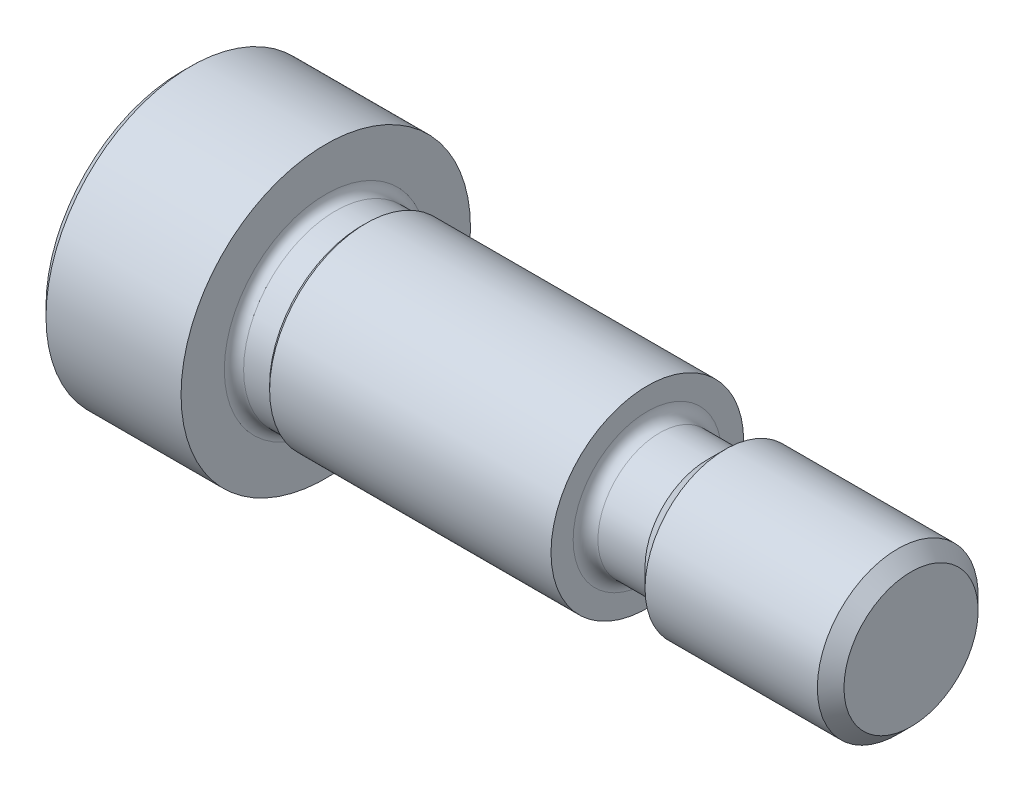
from build123d import *

# Parameters (mm, degrees)
CHAMFER1_SIZE = 0.6
HEX_2_DEPTH   = 4.9


with BuildPart() as part:
    # BodySke → BaseBody (revolve)
    with BuildSketch(Plane.XY):
        with BuildLine():
            Line((0, 0), (0, 9))
            Line((0, 9), (9, 9))
            Line((9, 9), (9, 6.31))
            ThreePointArc((9, 6.31), (9.175735931, 5.885735931), (9.6, 5.71))
            Line((9.6, 5.71), (11.218, 5.71))
            Line((11.218, 5.71), (11.5, 5.992))
            Line((11.5, 5.992), (29, 5.992))
            Line((29, 5.992), (29, 4.615))
            ThreePointArc((29, 4.615), (29.225527778, 4.070527778), (29.77, 3.845))
            Line((29.77, 3.845), (32.7, 3.845))
            Line((32.7, 3.845), (33.855, 5))
            Line((33.855, 5), (44.572, 5))
            Line((44.572, 5), (45.4, 4.172))
            Line((45.4, 4.172), (45.4, 0))
            Line((45.4, 0), (0, 0))
        make_face()
    revolve(axis=Axis((-6.35, 0, 0), (1, 0, 0)))

    # Chamfer1
    chamfer1_edges = [part.edges().sort_by_distance(p)[0] for p in [
        (0, -9, 0),
    ]]
    chamfer(chamfer1_edges, length=CHAMFER1_SIZE)

    # Sketch2 → PreBroach (revolve, cut)
    with BuildSketch(Plane.XY):
        Polygon((0, 3.0475), (4.9, 3.0475), (6.659474945, 0), (0, 0), align=None)
    revolve(axis=Axis((0, 0, 0), (1, 0, 0)), mode=Mode.SUBTRACT)

    # Sketch3 → Hex 2 (cut)
    with BuildSketch(Plane.ZY):
        Polygon((-3.0475, -1.759474945), (-3.0475, 1.759474945), (0, 3.518949891), (3.0475, 1.759474945), (3.0475, -1.759474945), (0, -3.518949891), align=None)
    extrude(amount=-HEX_2_DEPTH, mode=Mode.SUBTRACT)


solid = part.part
